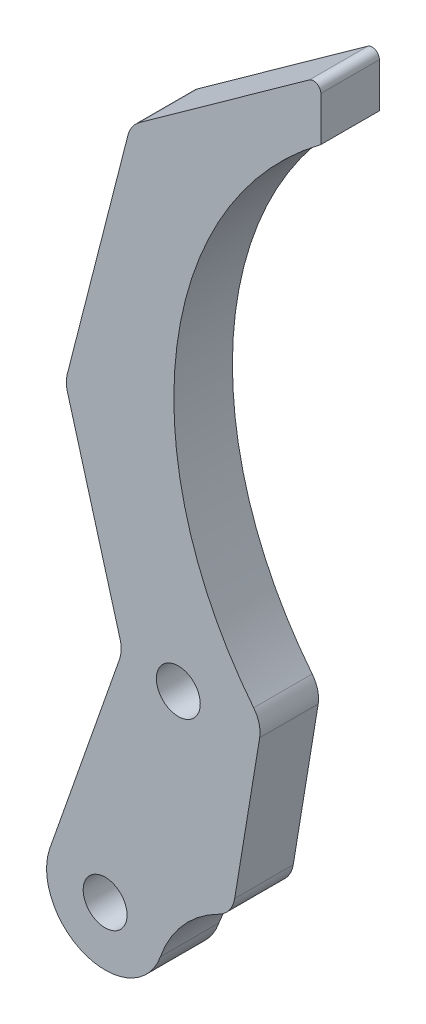
from build123d import *

# Parameters (mm, degrees)
SKETCH_1_R      = 1.5
EXTRUDE_1_DEPTH = 4


with BuildPart() as part:
    # 草图1 → 凸台-拉伸1 (new body)
    with BuildSketch(Plane.XY):
        with BuildLine():
            Line((-16.110282893, 33.654208826), (-17.814522763, 23.293438272))
            ThreePointArc((-17.814522763, 23.293438272), (-18.179793181, 22.42908037), (-18.899085656, 21.82645661))
            ThreePointArc((-18.899085656, 21.82645661), (-21.337272658, 19.958522776), (-22.891934151, 17.309568206))
            ThreePointArc((-22.891934151, 17.309568206), (-27.990948412, 14.860061819), (-30.440454799, 19.959076079))
            Line((-30.440454799, 19.959076079), (-25.681476272, 33.517536514))
            ThreePointArc((-25.681476272, 33.517536514), (-25.569637864, 34.115664062), (-25.6428361, 34.719738902))
            Line((-25.6428361, 34.719738902), (-29.24172024, 47.558366666))
            ThreePointArc((-29.24172024, 47.558366666), (-29.31581841, 48.075186607), (-29.253628902, 48.593574353))
            Line((-29.253628902, 48.593574353), (-25.108232608, 64.808221419))
            ThreePointArc((-25.108232608, 64.808221419), (-24.821945701, 65.441071196), (-24.336476636, 65.937839573))
            Line((-24.336476636, 65.937839573), (-12.719407819, 74.272976396))
            ThreePointArc((-12.719407819, 74.272976396), (-12.199607619, 74.311552327), (-11.927927269, 73.866726364))
            Line((-11.927927269, 73.866726364), (-11.927927269, 70.840856193))
            ThreePointArc((-11.927927269, 70.840856193), (-21.765630275, 54.0055336), (-16.519844581, 35.225485153))
            ThreePointArc((-16.519844581, 35.225485153), (-16.148427264, 34.483281689), (-16.110282893, 33.654208826))
        make_face()
        with Locations((-26.666194475, 18.634322143)):
            Circle(SKETCH_1_R, mode=Mode.SUBTRACT)
        with Locations((-21.666194475, 33.634322143)):
            Circle(SKETCH_1_R, mode=Mode.SUBTRACT)
    extrude(amount=EXTRUDE_1_DEPTH)


solid = part.part
